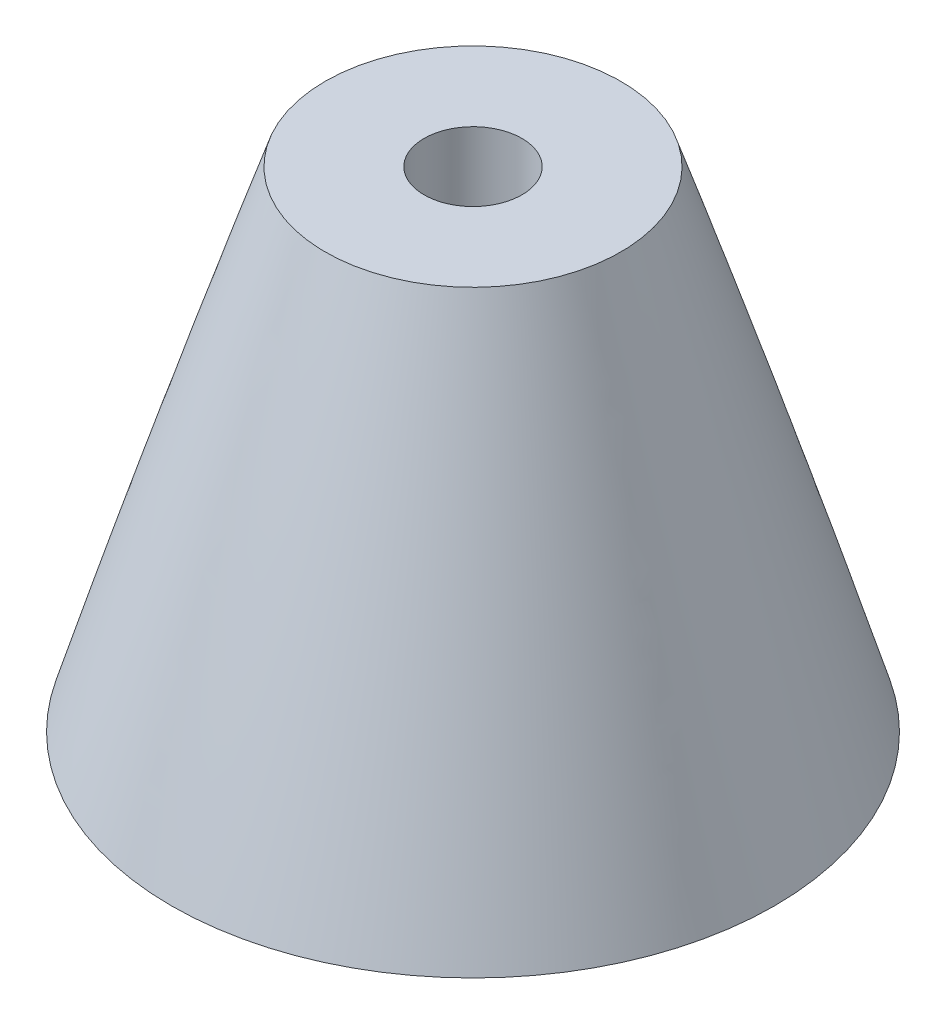
from build123d import *

# Parameters (mm, degrees)
SKETCH7_R          = 317.5
CUT_EXTRUDE2_DEPTH = 88.9
SKETCH10_R         = 85.772186651
CUT_EXTRUDE3_DEPTH = 254


with BuildPart() as part:
    # Sketch2 → Revolve1 (revolve)
    with BuildSketch(Plane.XY):
        with BuildLine():
            Line((-76.2, 0), (-69.85, 0))
            ThreePointArc((-69.85, 0), (-46.178344337, 164.977710697), (0, 325.12))
            Line((0, 325.12), (0, 330.2))
            ThreePointArc((0, 330.2), (-50.970594074, 168.070137094), (-76.2, 0))
        make_face()
    revolve(axis=Axis((0, 330.2, 0), (0, -1, 0)))

    # Sketch7 → Cut-Extrude2 (cut)
    with BuildSketch(Plane(origin=(0, 381, 0), x_dir=(1, 0, 0), z_dir=(0, 1, 0))):
        Circle(SKETCH7_R)
    extrude(amount=-CUT_EXTRUDE2_DEPTH, mode=Mode.SUBTRACT)


with BuildPart() as revolve2_tool:
    # Sketch9 → Revolve2 (revolve)
    with BuildSketch(Plane.XY):
        with BuildLine():
            Line((-3.81, 292.1), (-11.508581929, 292.1))
            add(Edge.make_bspline(
                [(-11.508581929, 292.1), (-17.806824774, 273.150147369), (-23.475281451, 254)],
                knots=[0, 0, 0, 1, 1, 1], degree=2))
            Line((-23.475281451, 254), (-17.611658866, 260.852181246))
            Line((-17.611658866, 260.852181246), (-10.246748418, 285.75))
            Line((-10.246748418, 285.75), (-3.81, 285.75))
            Line((-3.81, 285.75), (-3.81, 292.1))
        make_face()
    revolve(axis=Axis((0, 0, 0), (0, 1, 0)))


with BuildPart() as part_1:
    add(part.part)


with BuildPart() as part_2:
    # Revolve2: joined with revolve2_tool
    add(part_1.part.fuse(revolve2_tool.part, tol=0.00001))

    # Sketch10 → Cut-Extrude3 (cut)
    with BuildSketch(Plane.XZ):
        Circle(SKETCH10_R)
    extrude(amount=-CUT_EXTRUDE3_DEPTH, mode=Mode.SUBTRACT)

    # Sketch11 → Cut-Revolve1 (revolve, cut)
    with BuildSketch(Plane.XY):
        with BuildLine():
            Line((-11.508581929, 292.1), (-17.218255747, 292.1))
            Line((-17.218255747, 292.1), (-28.877637537, 252.581941016))
            Line((-28.877637537, 252.581941016), (-23.475281451, 254))
            add(Edge.make_bspline(
                [(-23.475281451, 254), (-17.807210235, 273.148920026), (-11.508581929, 292.1)],
                knots=[0, 0, 0, 1, 1, 1], degree=2))
        make_face()
    revolve(axis=Axis((0, 292.1, 0), (0, -1, 0)), mode=Mode.SUBTRACT)


solid = part_2.part
